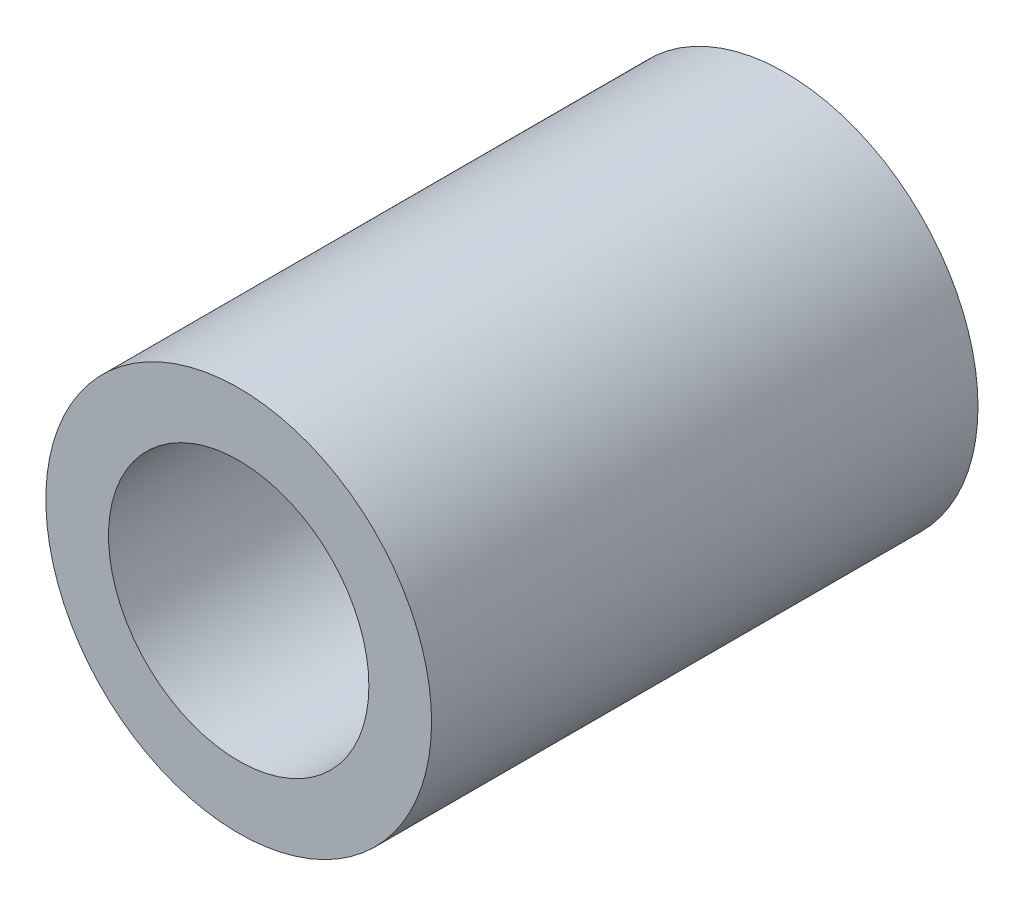
from build123d import *

# Parameters (mm, degrees)
ESQUISSE1_R      = 3
ESQUISSE1_R_2    = 2.025
EXTRUSION1_DEPTH = 4.25


with BuildPart() as part:
    # Esquisse1 → Extrusion1 (new body, symmetric)
    with BuildSketch(Plane.XY):
        Circle(ESQUISSE1_R)
        Circle(ESQUISSE1_R_2, mode=Mode.SUBTRACT)
    extrude(amount=EXTRUSION1_DEPTH, both=True)


solid = part.part
